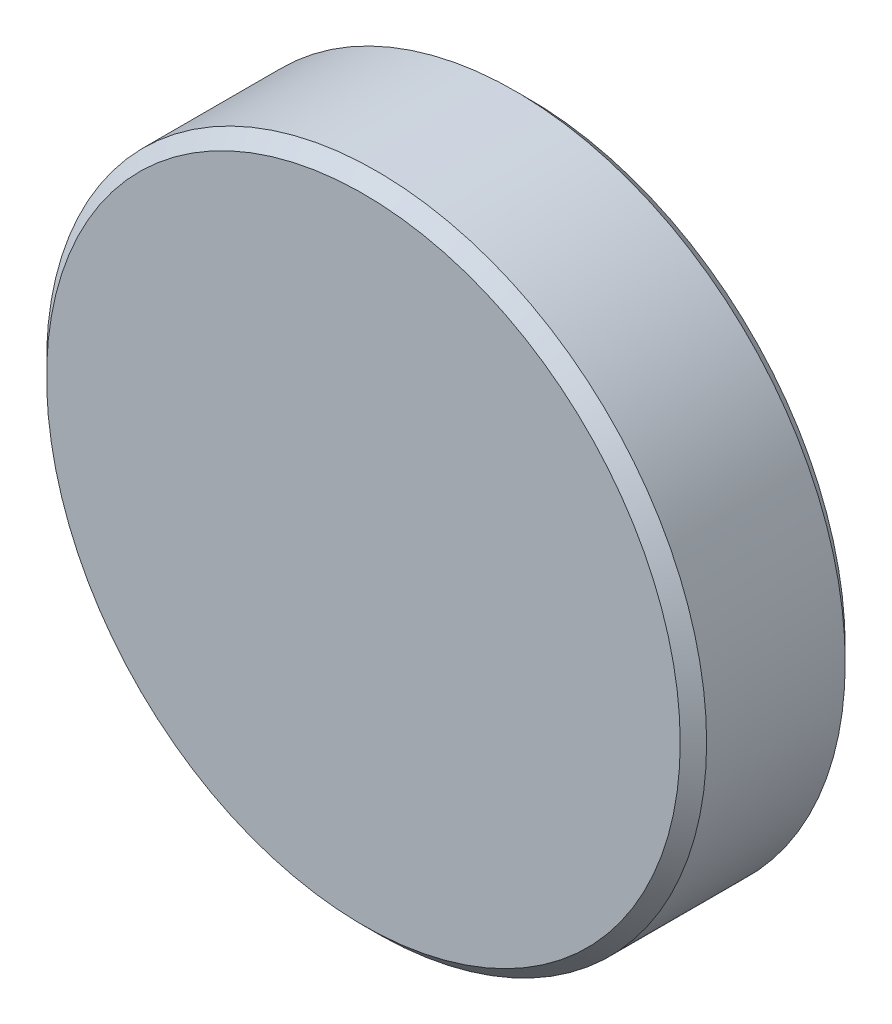
from build123d import *

# Parameters (mm, degrees)
ESQUISSE1_R        = 100
BOSS_EXTRU_1_DEPTH = 50
CHANFREIN1_SIZE    = 4
CHANFREIN2_SIZE    = 4


with BuildPart() as part:
    # Esquisse1 → Boss.-Extru.1 (new body)
    with BuildSketch(Plane.XY):
        Circle(ESQUISSE1_R)
    extrude(amount=BOSS_EXTRU_1_DEPTH)

    # Chanfrein1
    chanfrein1_edges = [part.edges().sort_by_distance(p)[0] for p in [
        (-100, 0, 0),
    ]]
    chamfer(chanfrein1_edges, length=CHANFREIN1_SIZE)

    # Chanfrein2
    chanfrein2_edges = [part.edges().sort_by_distance(p)[0] for p in [
        (-100, 0, 50),
    ]]
    chamfer(chanfrein2_edges, length=CHANFREIN2_SIZE)


solid = part.part
